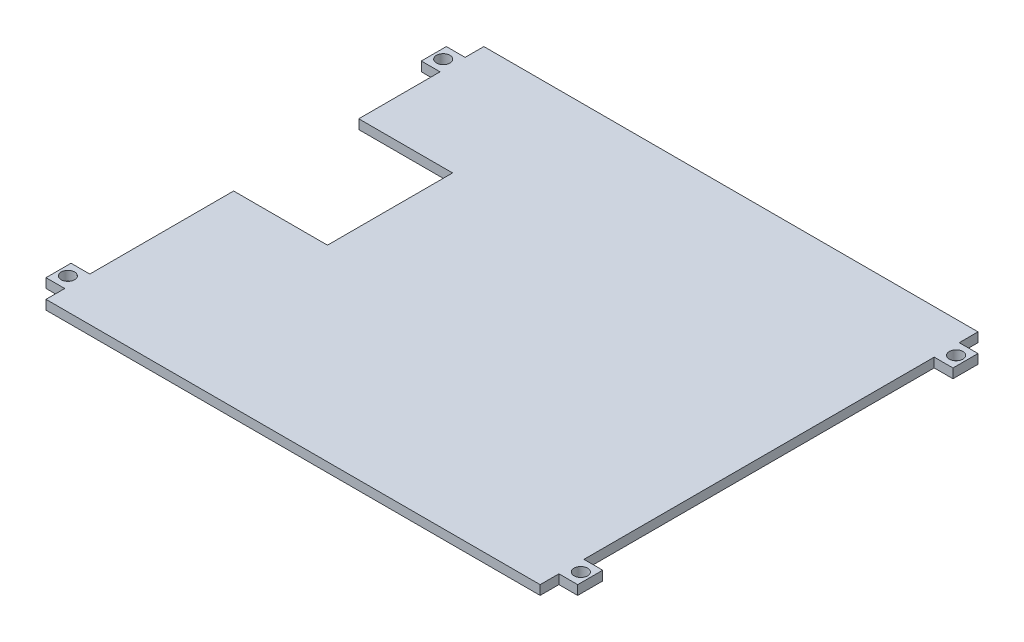
from build123d import *

# Parameters (mm, degrees)
BOSS_EXTRUDE1_DEPTH  = 1.5
SKETCH3_W            = 4
SKETCH3_H            = 1.5
BOSS_EXTRUDE2_DEPTH  = 3
SKETCH4_R            = 1.08
CUT_EXTRUDE1_DEPTH   = 2.5
LPATTERN1_COUNT      = 2
LPATTERN1_PITCH      = 60
LPATTERN1_COUNT_DIR2 = 2
LPATTERN1_PITCH_DIR2 = 82
LPATTERN2_COUNT      = 2
LPATTERN2_PITCH      = 60
LPATTERN2_COUNT_DIR2 = 2
LPATTERN2_PITCH_DIR2 = 82


with BuildPart() as part:
    # Sketch2 → Boss-Extrude1 (new body)
    with BuildSketch(Plane(origin=(0, 0, 0), x_dir=(1, 0, 0), z_dir=(0, 1, 0))):
        Polygon((0, 0), (79, 0), (79, 70), (0, 70), (0, 50), (15, 50), (15, 30), (0, 30), align=None)
    extrude(amount=BOSS_EXTRUDE1_DEPTH)

    # Sketch3 → Boss-Extrude2 (add)
    with BuildSketch(Plane(origin=(79, 0, 0), x_dir=(0, 0, -1), z_dir=(1, 0, 0))):
        with Locations((5, 0.75)):
            Rectangle(SKETCH3_W, SKETCH3_H)
    boss_extrude2 = extrude(amount=BOSS_EXTRUDE2_DEPTH)

    # Sketch4 → Cut-Extrude1 (cut, through all)
    with BuildSketch(Plane(origin=(0, 1.5, 0), x_dir=(1, 0, 0), z_dir=(0, 1, 0))):
        with Locations((80.5, 5)):
            Circle(SKETCH4_R)
    cut_extrude1 = extrude(amount=-CUT_EXTRUDE1_DEPTH, mode=Mode.SUBTRACT)

    # LPattern1: Boss-Extrude2 2 × 2
    with Locations(*[(-j * LPATTERN1_PITCH_DIR2, 0, -i * LPATTERN1_PITCH) for i in range(LPATTERN1_COUNT) for j in range(LPATTERN1_COUNT_DIR2) if (i, j) != (0, 0)]):
        add(boss_extrude2)

    # LPattern2: Cut-Extrude1 2 × 2
    with Locations(*[(-j * LPATTERN2_PITCH_DIR2, 0, -i * LPATTERN2_PITCH) for i in range(LPATTERN2_COUNT) for j in range(LPATTERN2_COUNT_DIR2) if (i, j) != (0, 0)]):
        add(cut_extrude1, mode=Mode.SUBTRACT)


solid = part.part
